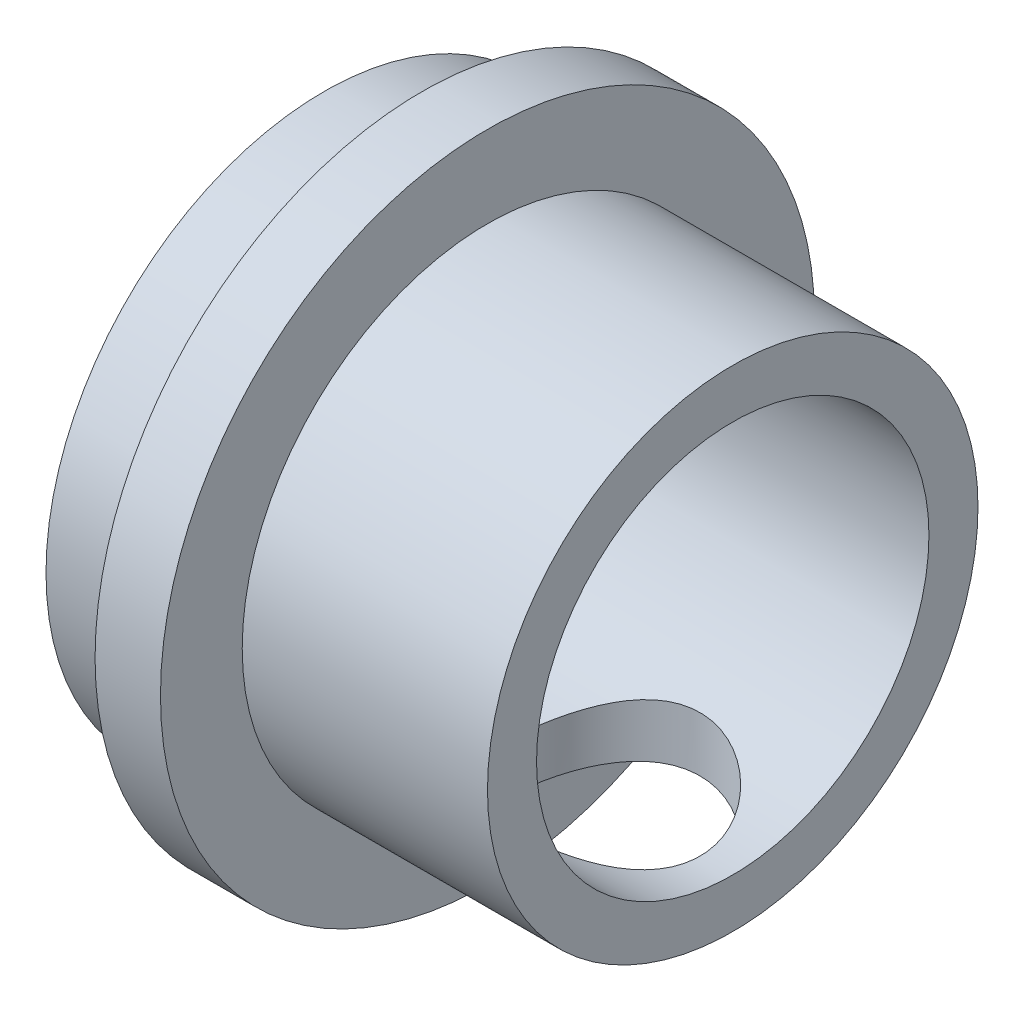
from build123d import *

# Parameters (mm, degrees)
ESQUISSE2_W             = 8
ESQUISSE2_H             = 8
ENL_V_MAT_EXTRU_1_DEPTH = 13.5
ESQUISSE3_R             = 6
ENL_V_MAT_EXTRU_2_DEPTH = 10
ESQUISSE4_R             = 3
ENL_V_MAT_EXTRU_3_DEPTH = 10


with BuildPart() as part:
    # Esquisse1 → Révolution1 (revolve)
    with BuildSketch(Plane.XY):
        Polygon((0, 0), (0, 8.5), (3, 8.5), (3, 9.093663992), (3, 10), (5, 10), (5, 7.5), (12.5, 7.5), (12.5, 0), align=None)
    revolve(axis=Axis((-59.603539616, 0, 0), (1, 0, 0)))

    # Esquisse2 → Enlèv. mat.-Extru.1 (cut, through all)
    with BuildSketch(Plane.ZY):
        Rectangle(ESQUISSE2_W, ESQUISSE2_H)
    extrude(amount=-ENL_V_MAT_EXTRU_1_DEPTH, mode=Mode.SUBTRACT)

    # Esquisse3 → Enlèv. mat.-Extru.2 (cut)
    with BuildSketch(Plane(origin=(12.5, 0, 0), x_dir=(0, 0, -1), z_dir=(1, 0, 0))):
        Circle(ESQUISSE3_R)
    extrude(amount=-ENL_V_MAT_EXTRU_2_DEPTH, mode=Mode.SUBTRACT)

    # Esquisse4 → Enlèv. mat.-Extru.3 (cut)
    with BuildSketch(Plane(origin=(0, 0, 0), x_dir=(1, 0, 0), z_dir=(0, 1, 0))):
        with Locations((8.5, 0)):
            Circle(ESQUISSE4_R)
    extrude(amount=-ENL_V_MAT_EXTRU_3_DEPTH, mode=Mode.SUBTRACT)


solid = part.part
